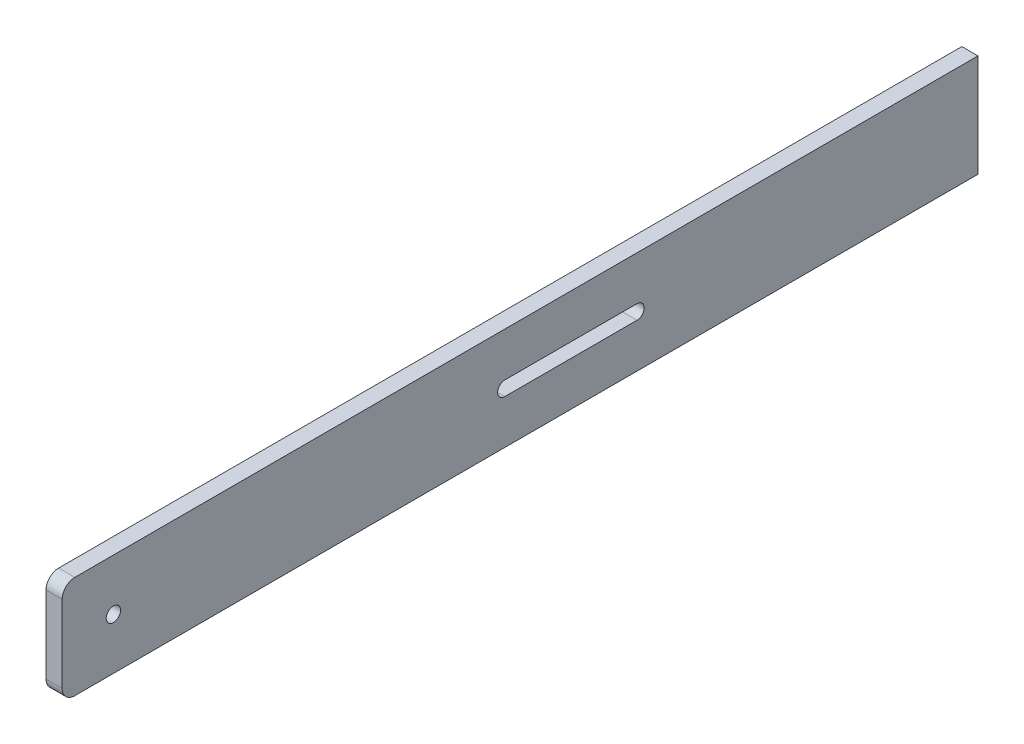
from build123d import *

# Parameters (mm, degrees)
SKETCH1_W           = 3.175
SKETCH1_H           = 20.17
BOSS_EXTRUDE1_DEPTH = 180.17
SKETCH6_R           = 1.415
CUT_EXTRUDE1_DEPTH  = 181.479962184
FILLET1_R           = 2.5
CUT_EXTRUDE3_DEPTH  = 10


with BuildPart() as part:
    # Sketch1 → Boss-Extrude1 (new body)
    with BuildSketch(Plane.XY):
        Rectangle(SKETCH1_W, SKETCH1_H)
    extrude(amount=BOSS_EXTRUDE1_DEPTH)

    # Sketch6 → Cut-Extrude1 (cut, through all)
    with BuildSketch(Plane(origin=(1.5875, 0, 0), x_dir=(0, 0, -1), z_dir=(1, 0, 0))):
        with Locations((-170.085, 0)):
            Circle(SKETCH6_R)
    extrude(amount=-CUT_EXTRUDE1_DEPTH, mode=Mode.SUBTRACT)

    # Fillet1
    fillet1_edges = [part.edges().sort_by_distance(p)[0] for p in [
        (0, -10.085, 180.17),
        (0, 10.085, 180.17),
    ]]
    fillet(fillet1_edges, radius=FILLET1_R)

    # Sketch7 → Cut-Extrude3 (cut)
    with BuildSketch(Plane.ZY.offset(1.5875)):
        with BuildLine():
            Line((67.085, 1.415), (93.085, 1.415))
            ThreePointArc((93.085, 1.415), (94.5, 0), (93.085, -1.415))
            Line((93.085, -1.415), (67.085, -1.415))
            ThreePointArc((67.085, -1.415), (65.67, 0), (67.085, 1.415))
        make_face()
    extrude(amount=-CUT_EXTRUDE3_DEPTH, mode=Mode.SUBTRACT)


solid = part.part
